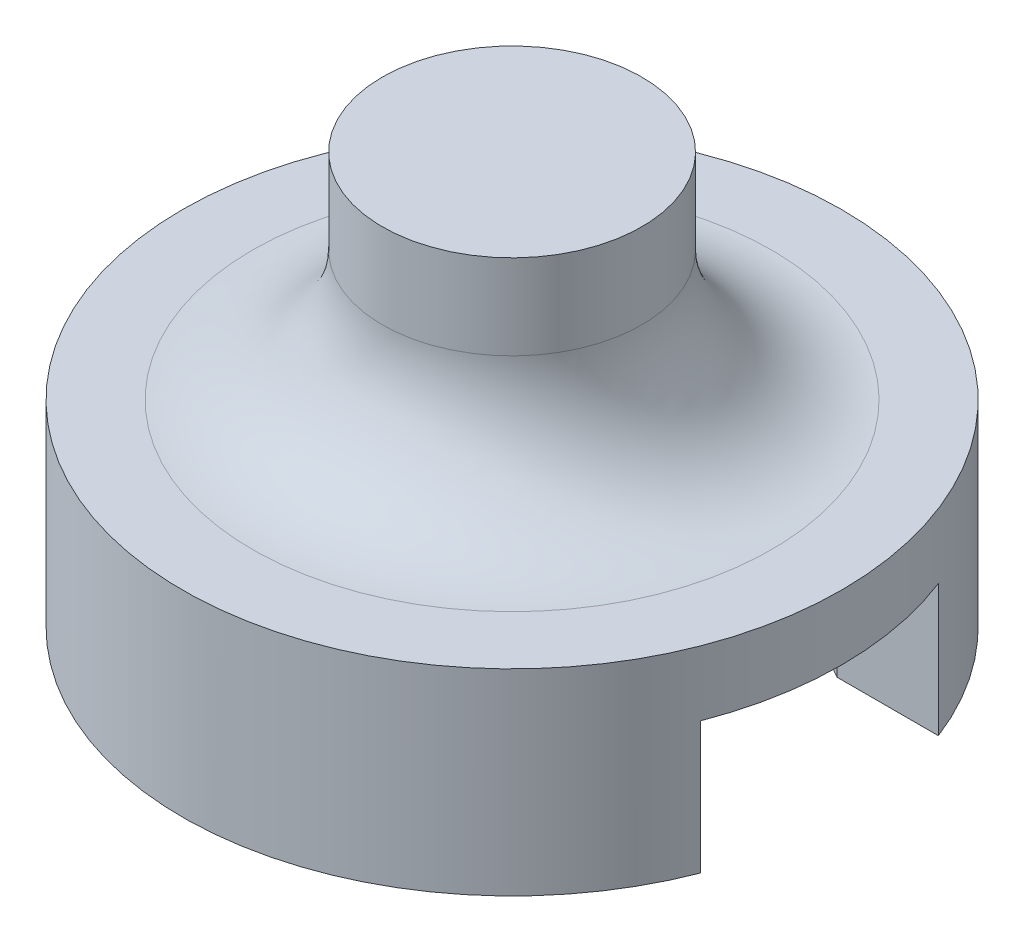
from build123d import *

# Parameters (mm, degrees)
BOSS_EXTRUDE1_DEPTH = 25.4
BOSS_EXTRUDE3_DEPTH = 5.08
SKETCH4_W           = 37.4
SKETCH4_H           = 25.4
CUT_EXTRUDE1_DEPTH  = 25.4
SKETCH5_R           = 12.7
BOSS_EXTRUDE4_DEPTH = 2.5
SKETCH6_R           = 5
BOSS_EXTRUDE5_DEPTH = 8.272
FILLET1_R           = 5


with BuildPart() as part:
    # Sketch1 → Boss-Extrude1 (new body)
    with BuildSketch(Plane.XY):
        Polygon((-10.189534884, 0), (-10.189534884, 9), (15.210465116, 9), (15.210465116, 0), (21.210465116, 0), (21.210465116, 20.17346), (-16.189534884, 20.17346), (-16.189534884, 0), align=None)
    extrude(amount=BOSS_EXTRUDE1_DEPTH)

    # Sketch3 → Boss-Extrude3 (add)
    with BuildSketch(Plane(origin=(0, 20.17346, 0), x_dir=(1, 0, 0), z_dir=(0, 1, 0))):
        with BuildLine():
            Line((14.354818113, -17.282717762), (10.447965116, -17.282717762))
            Line((10.447965116, -17.282717762), (2.510465116, -21.865435523))
            Line((2.510465116, -21.865435523), (-5.427034884, -17.282717762))
            Line((-5.427034884, -17.282717762), (-5.427034884, -8.117282238))
            Line((-5.427034884, -8.117282238), (2.510465116, -3.534564477))
            Line((2.510465116, -3.534564477), (10.447965116, -8.117282238))
            Line((10.447965116, -8.117282238), (14.354818113, -8.117282238))
            ThreePointArc((14.354818113, -8.117282238), (-10.189534884, -12.7), (14.354818113, -17.282717762))
        make_face()
    extrude(amount=BOSS_EXTRUDE3_DEPTH)

    # Sketch4 → Cut-Extrude1 (cut)
    with BuildSketch(Plane(origin=(0, 20.17346, 0), x_dir=(1, 0, 0), z_dir=(0, 1, 0))):
        with Locations((2.510465116, -12.7)):
            Rectangle(SKETCH4_W, SKETCH4_H)
    extrude(amount=-CUT_EXTRUDE1_DEPTH, mode=Mode.SUBTRACT)

    # Sketch5 → Boss-Extrude4 (add)
    with BuildSketch(Plane(origin=(0, 25.25346, 0), x_dir=(1, 0, 0), z_dir=(0, 1, 0))):
        with Locations((2.510465116, -12.7)):
            Circle(SKETCH5_R)
    extrude(amount=BOSS_EXTRUDE4_DEPTH)

    # Sketch6 → Boss-Extrude5 (add)
    with BuildSketch(Plane(origin=(0, 27.75346, 0), x_dir=(1, 0, 0), z_dir=(0, 1, 0))):
        with Locations((2.510465116, -12.7)):
            Circle(SKETCH6_R)
    extrude(amount=BOSS_EXTRUDE5_DEPTH)

    # Fillet1
    fillet1_edges = [part.edges().sort_by_distance(p)[0] for p in [
        (-2.489534884, 27.75346, 12.7),
    ]]
    fillet(fillet1_edges, radius=FILLET1_R)


solid = part.part
